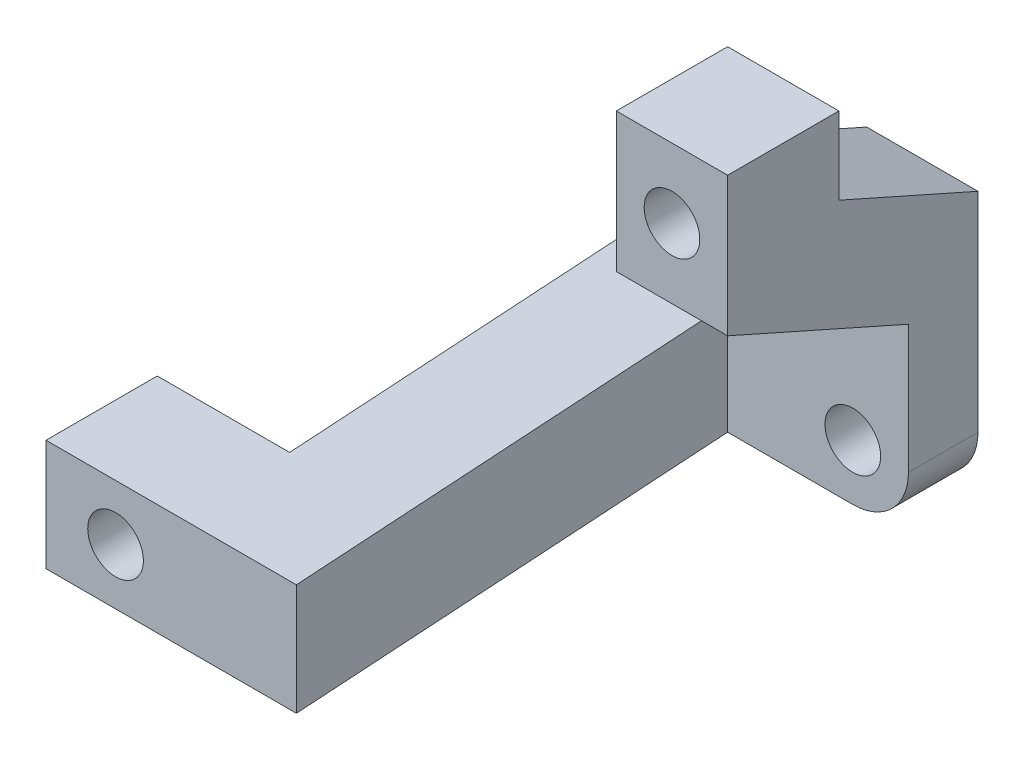
from build123d import *

# Parameters (mm, degrees)
SKETCH_1_R          = 2
EXTRUDE_1_DEPTH     = 5
SKETCH_7_W          = 8
SKETCH_7_H          = 8
SKETCH_6_W          = 8
SKETCH_6_H          = 8
SKETCH_9_W          = 8
SKETCH_9_H          = 8
EXTRUDE_5_DEPTH     = 10
SKETCH_1_6_R        = 2
CUT_EXTRUDE_2_DEPTH = 99
SKETCH_14_W         = 8
SKETCH_14_H         = 8
SKETCH_15_W         = 8
SKETCH_15_H         = 8
EXTRUDE_7_REACH     = 31
SKETCH_17_W         = 8
SKETCH_17_H         = 8
SKETCH_1_7_R        = 2
CUT_EXTRUDE_4_DEPTH = 33.5


with BuildPart() as part:
    # 草图1 → 凸台-拉伸1 (new body)
    with BuildSketch(Plane.XY):
        with BuildLine():
            Line((-15, 4), (-15, -4))
            Line((-15, -4), (0, -4))
            ThreePointArc((0, -4), (2.828427125, -2.828427125), (4, 0))
            Line((4, 0), (4, 15))
            Line((4, 15), (-4, 15))
            Line((-4, 15), (-4, 8))
            ThreePointArc((-4, 8), (-5.171572875, 5.171572875), (-8, 4))
            Line((-8, 4), (-15, 4))
        make_face()
        Circle(SKETCH_1_R, mode=Mode.SUBTRACT)
    extrude(amount=EXTRUDE_1_DEPTH)

    # 草图7 → 放样2 section 0
    with BuildSketch(Plane.XY.offset(5)):
        with Locations((-13, 0)):
            Rectangle(SKETCH_7_W, SKETCH_7_H)
    # 草图6 → 放样2 section 1
    with BuildSketch(Plane.XY.offset(38)):
        with Locations((-11, 0)):
            Rectangle(SKETCH_6_W, SKETCH_6_H)
    loft()

    # 草图9 → 凸台-拉伸5 (add)
    with BuildSketch(Plane(origin=(-25, 0, 0), x_dir=(0, 0, -1), z_dir=(1, 0, 0))):
        with Locations((-34, 0)):
            Rectangle(SKETCH_9_W, SKETCH_9_H)
    extrude(amount=EXTRUDE_5_DEPTH)

    # 草图1<6> → 切除-拉伸2 (cut)
    with BuildSketch(Plane.XY):
        with Locations((-20, 0)):
            Circle(SKETCH_1_6_R)
    extrude(amount=CUT_EXTRUDE_2_DEPTH, mode=Mode.SUBTRACT)

    # 草图14 → 放样3 section 0
    with BuildSketch(Plane.XY):
        with Locations((0, 11)):
            Rectangle(SKETCH_14_W, SKETCH_14_H)
    # 草图15 → 放样3 section 1
    with BuildSketch(Plane.XY.offset(18)):
        with Locations((0, 19)):
            Rectangle(SKETCH_15_W, SKETCH_15_H)
    loft()

    # 凸台-拉伸7: up to this face of the body (flat: up to its plane)
    extrude_7_end = Plane(part.part.faces().sort_by_distance((0, 19, 9))[0])
    # 草图17 → 凸台-拉伸7 (add, up to the picked face)
    with BuildSketch(Plane(origin=(0, 25, 0), x_dir=(1, 0, 0), z_dir=(0, 1, 0)), mode=Mode.PRIVATE) as extrude_7_sk1:
        with Locations((0, -14)):
            Rectangle(SKETCH_17_W, SKETCH_17_H)
    extrude_7_tool1 = split(extrude(extrude_7_sk1.sketch, amount=-EXTRUDE_7_REACH, mode=Mode.PRIVATE), bisect_by=extrude_7_end, keep=Keep.BOTH, mode=Mode.PRIVATE)
    add(extrude_7_tool1.solids().sort_by_distance((0, 25, 14))[0])

    # 草图1<7> → 切除-拉伸4 (cut)
    with BuildSketch(Plane.XY):
        with Locations((0, 20)):
            Circle(SKETCH_1_7_R)
    extrude(amount=CUT_EXTRUDE_4_DEPTH, mode=Mode.SUBTRACT)


solid = part.part
